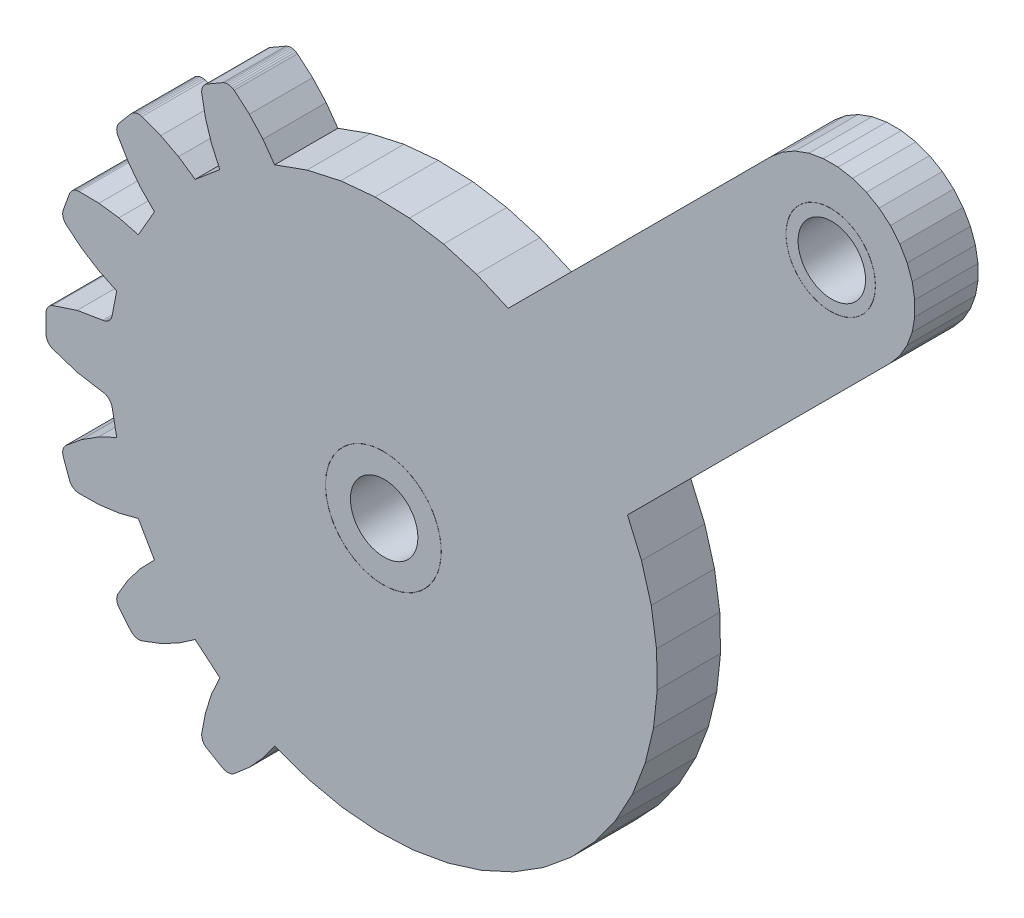
from build123d import *

# Parameters (mm, degrees)
BOSS_EXTRUDE1_DEPTH = 3.000000026
SKETCH2_R           = 2.739535321
BOSS_EXTRUDE2_DEPTH = 3
SKETCH4_W           = 1.6
SKETCH4_H           = 3.000000026
SKETCH5_R           = 2.116912565
BOSS_EXTRUDE3_DEPTH = 3
SKETCH7_W           = 1.6
SKETCH7_H           = 3.000000026


with BuildPart() as part:
    # Sketch1 → Boss-Extrude1 (new body)
    with BuildSketch(Plane.XY.offset(3.000000026)):
        Polygon((30.938014388, 12.52672635), (30.993692577, 12.464644387), (31.038278714, 12.394173071), (31.070532277, 12.317270041), (31.089555472, 12.236077338), (31.302556396, 11.128782295), (30.442863703, 10.716496967), (29.638325796, 10.204861872), (28.900368139, 9.601146914), (28.843764216, 9.539354593), (28.798276559, 9.468976408), (28.765179217, 9.39199049), (28.745405376, 9.310557507), (28.739510104, 9.226966649), (28.747657314, 9.14356485), (28.7696179, 9.062694386), (29.060218483, 8.264278062), (29.095377773, 8.188211359), (29.142744839, 8.119084872), (29.200993478, 8.058840409), (29.268484563, 8.009170182), (29.343323782, 7.971468382), (29.42340821, 7.946795784), (29.506489635, 7.93584343), (30.459856614, 7.947720587), (31.405042857, 8.072933182), (32.328616828, 8.309704252), (33.093754202, 6.98444806), (32.426916063, 6.302993745), (31.84588626, 5.547046661), (31.358916312, 4.727343097), (31.326860189, 4.649917595), (31.308189034, 4.568225704), (31.303416938, 4.484563135), (31.312689185, 4.401278682), (31.335737556, 4.320711829), (31.371917576, 4.245125689), (31.420215964, 4.176644608), (31.966362149, 3.525769338), (32.025419176, 3.466315567), (32.093573362, 3.417558968), (32.168913633, 3.380868584), (32.249324024, 3.357278183), (32.332543284, 3.347447142), (32.416235656, 3.351651132), (32.498050481, 3.369776532), (33.389862627, 3.707006341), (34.235220402, 4.147941247), (35.022117198, 4.686314613), (36.194376647, 3.702674061), (35.800825804, 2.8342437), (35.51338613, 1.925161108), (35.336136818, 0.988340005), (35.332497209, 0.904619694), (35.342887044, 0.821467547), (35.367019475, 0.741219148), (35.404216498, 0.666126609), (35.453431308, 0.598302111), (35.513281822, 0.53964922), (35.582087934, 0.49181655), (36.317910999, 0.06698817), (36.393739283, 0.031316653), (36.474458873, 0.008810312), (36.557804793, 0.000102445), (36.641433835, 0.005435199), (36.722999066, 0.024659559), (36.800205708, 0.057237223), (36.870889366, 0.102249905), (37.593577057, 0.724161044), (38.237147033, 1.427633688), (38.792453706, 2.202672884), (40.370669216, 1.638272777), (42.008381337, 1.281620935), (43.678373098, 1.138646156), (45.352879912, 1.211725292), (47.004066408, 1.499641687), (48.604480922, 1.997612417), (50.127528608, 2.697357908), (51.547884941, 3.587245941), (52.841939032, 4.65248432), (53.988181055, 5.875365809), (54.967559874, 7.235560566), (55.763788521, 8.710460737), (56.363634765, 10.27554553), (56.757129729, 11.904801242), (56.937731802, 13.57114315), (56.902434677, 15.246870928), (56.651826948, 16.904130578), (56.19007349, 18.515370786), (55.524855852, 20.053809509), (67.991629243, 32.520584762), (68.439811468, 33.054705709), (68.788431585, 33.658538014), (69.026909769, 34.313734621), (69.147981703, 35.000387579), (69.147981703, 35.697635263), (69.026909769, 36.384288222), (68.788431585, 37.039484829), (68.439811468, 37.643317133), (67.991629243, 38.17743808), (67.457512021, 38.625620306), (66.853687167, 38.974240422), (66.198483109, 39.212714881), (65.511822701, 39.333790541), (64.814582467, 39.333790541), (64.127929509, 39.212714881), (63.472732902, 38.974240422), (62.868900597, 38.625620306), (62.33477965, 38.17743808), (49.868002534, 25.710662827), (48.36897552, 26.361709461), (46.800114214, 26.819532737), (45.186202973, 27.076898143), (43.552760035, 27.12973766), (41.925594211, 26.977216825), (40.33042118, 26.621745899), (38.792453706, 26.068942621), (38.237147033, 26.84398368), (37.593577057, 27.547456324), (36.870889366, 28.169367462), (36.800205708, 28.214380145), (36.722999066, 28.246957809), (36.641433835, 28.266180307), (36.557804793, 28.271514922), (36.474458873, 28.262805194), (36.393739283, 28.240300715), (36.317910999, 28.204629198), (35.582087934, 27.779800817), (35.513281822, 27.731966227), (35.453431308, 27.673315257), (35.404216498, 27.605488896), (35.367019475, 27.53039822), (35.342887044, 27.450149879), (35.332497209, 27.366997674), (35.336136818, 27.283277363), (35.51338613, 26.346456259), (35.800825804, 25.437373668), (36.194376647, 24.568943307), (35.022117198, 23.585300893), (34.235220402, 24.123676121), (33.389862627, 24.564608932), (32.498050481, 24.901840836), (32.416235656, 24.919964373), (32.332543284, 24.924170226), (32.249324024, 24.914339185), (32.168913633, 24.890746921), (32.093573362, 24.8540584), (32.025419176, 24.8053018), (31.966362149, 24.74584803), (31.420215964, 24.094972759), (31.371917576, 24.026490748), (31.335737556, 23.950904608), (31.312689185, 23.870337754), (31.303416938, 23.787053302), (31.308189034, 23.703390732), (31.326860189, 23.621698841), (31.358916312, 23.544274271), (31.84588626, 22.724570706), (32.426916063, 21.968623623), (33.093754202, 21.287169307), (32.328616828, 19.961912185), (31.405042857, 20.198684186), (30.459856614, 20.323896781), (29.506489635, 20.335773006), (29.42340821, 20.324820653), (29.343323782, 20.300148055), (29.268484563, 20.262446254), (29.200993478, 20.212776959), (29.142744839, 20.152531564), (29.095377773, 20.083405077), (29.060218483, 20.007338375), (28.7696179, 19.208922982), (28.747657314, 19.128052518), (28.739510104, 19.044650719), (28.745405376, 18.96105893), (28.765179217, 18.879625946), (28.798276559, 18.80264096), (28.843764216, 18.732262775), (28.900368139, 18.670469522), (29.638325796, 18.066754565), (30.442863703, 17.55511947), (31.302556396, 17.142834142), (31.089555472, 16.035540029), (31.070532277, 15.954345465), (31.038278714, 15.877444297), (30.993692577, 15.80697298), (30.938014388, 15.744891018), (30.872792006, 15.692926943), (30.799839646, 15.65252617), (30.721187592, 15.624811873), (30.639022589, 15.610555187), (29.425321147, 15.408091247), (28.257027268, 15.021897852), (28.182702139, 14.983191155), (28.115887195, 14.932615682), (28.058454394, 14.871591702), (28.012022376, 14.801833779), (27.977891266, 14.725299552), (27.95702219, 14.644141309), (27.950000018, 14.560637064), (27.950000018, 13.710979372), (27.95702219, 13.627475128), (27.977891266, 13.546316884), (28.012022376, 13.469783589), (28.058454394, 13.400025666), (28.115887195, 13.339001685), (28.182702139, 13.288425282), (28.257027268, 13.249719515), (29.425321147, 12.863526121), (30.639022589, 12.661062181), (30.721187592, 12.646805495), (30.799839646, 12.619091198), (30.872792006, 12.578690425), align=None)
        Polygon((41.241779923, 13.658275828), (41.200000793, 14.135807753), (41.241779923, 14.61334154), (41.365846992, 15.076363459), (41.568428278, 15.510808676), (41.843377054, 15.903474763), (42.182333767, 16.242429614), (42.575001717, 16.51737839), (43.009445071, 16.719963402), (43.472468853, 16.84403047), (43.949998915, 16.885807738), (44.427532703, 16.84403047), (44.890556484, 16.719963402), (45.324999839, 16.51737839), (45.717667788, 16.242429614), (46.056620777, 15.903474763), (46.331569552, 15.510808676), (46.534154564, 15.076363459), (46.658221632, 14.61334154), (46.700000763, 14.135807753), (46.658221632, 13.658275828), (46.534154564, 13.195252977), (46.331569552, 12.760808691), (46.056620777, 12.368143536), (45.717667788, 12.029185891), (45.324999839, 11.754238978), (44.890556484, 11.551653966), (44.427532703, 11.427586898), (43.949998915, 11.385808699), (43.472468853, 11.427586898), (43.009445071, 11.551653966), (42.575001717, 11.754238978), (42.182333767, 12.029185891), (41.843377054, 12.368143536), (41.568428278, 12.760808691), (41.365846992, 13.195252977), align=None, mode=Mode.SUBTRACT)
        Polygon((65.88999927, 33.352166414), (65.53221494, 33.256296068), (65.163202584, 33.224012703), (64.794197679, 33.256296068), (64.436413348, 33.352166414), (64.100705087, 33.508706838), (63.797280192, 33.721167594), (63.535362482, 33.98308903), (63.322901726, 34.286513925), (63.166357577, 34.62221846), (63.070483506, 34.980010241), (63.03820014, 35.349011421), (63.070483506, 35.718016326), (63.166357577, 36.075804383), (63.322901726, 36.411512643), (63.535362482, 36.714933813), (63.797280192, 36.976858974), (64.100705087, 37.189316005), (64.436413348, 37.345856428), (64.794197679, 37.441730499), (65.163202584, 37.474013865), (65.53221494, 37.441730499), (65.88999927, 37.345856428), (66.22570008, 37.189316005), (66.529124975, 36.976858974), (66.791050136, 36.714933813), (67.003510892, 36.411512643), (67.160047591, 36.075804383), (67.255921662, 35.718016326), (67.288205028, 35.349011421), (67.255921662, 34.980010241), (67.160047591, 34.62221846), (67.003510892, 34.286513925), (66.791050136, 33.98308903), (66.529124975, 33.721167594), (66.22570008, 33.508706838), align=None, mode=Mode.SUBTRACT)
    extrude(amount=-BOSS_EXTRUDE1_DEPTH)


with BuildPart() as body_2:
    # Sketch2 → Boss-Extrude2 (new body)
    with BuildSketch(Plane.XY.offset(3.000000026)):
        with Locations((43.949999847, 14.135808451)):
            Circle(SKETCH2_R)
    extrude(amount=-BOSS_EXTRUDE2_DEPTH)

    # Sketch4 → M3 Clearance Hole1 (revolve, cut)
    with BuildSketch(Plane(origin=(43.985619066, 14.149518848, 3.000000026), x_dir=(0, -1, 0), z_dir=(1, 0, 0))):
        with Locations((0.8, 1.500000013)):
            Rectangle(SKETCH4_W, SKETCH4_H)
    revolve(axis=Axis((43.985619066, 14.149518848, 9.350000026), (0, 0, -1)), mode=Mode.SUBTRACT)


with BuildPart() as body_3:
    # Sketch5 → Boss-Extrude3 (new body)
    with BuildSketch(Plane.XY.offset(3.000000026)):
        with Locations((65.163206309, 35.349012353)):
            Circle(SKETCH5_R)
    extrude(amount=-BOSS_EXTRUDE3_DEPTH)

    # Sketch7 → M3 Clearance Hole2 (revolve, cut)
    with BuildSketch(Plane(origin=(65.214166807, 35.356838534, 3.000000026), x_dir=(0, -1, 0), z_dir=(1, 0, 0))):
        with Locations((0.8, 1.500000013)):
            Rectangle(SKETCH7_W, SKETCH7_H)
    revolve(axis=Axis((65.214166807, 35.356838534, 9.350000026), (0, 0, -1)), mode=Mode.SUBTRACT)


solid = Compound([part.part, body_2.part, body_3.part])
